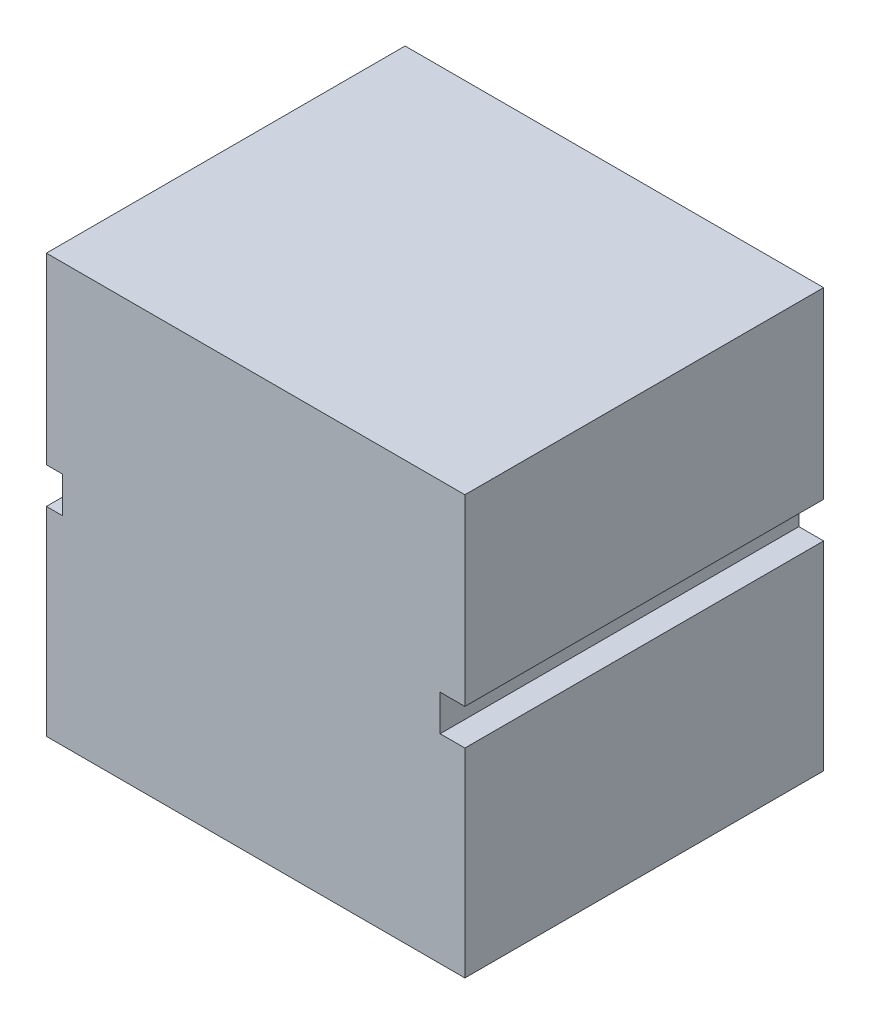
from build123d import *

# Parameters (mm, degrees)
ESQUISSE1_W             = 7
ESQUISSE1_H             = 7
BOSS_EXTRU_1_DEPTH      = 6
ESQUISSE2_W             = 0.413980681
ESQUISSE2_H             = 0.602508534
ESQUISSE2_W_2           = 0.26702738
ENL_V_MAT_EXTRU_1_DEPTH = 7


with BuildPart() as part:
    # Esquisse1 → Boss.-Extru.1 (new body)
    with BuildSketch(Plane.XY):
        with Locations((3.5, 3.5)):
            Rectangle(ESQUISSE1_W, ESQUISSE1_H)
    extrude(amount=BOSS_EXTRU_1_DEPTH)

    # Esquisse2 → Enlèv. mat.-Extru.1 (cut, through all)
    with BuildSketch(Plane(origin=(0, 0, 0), x_dir=(-1, 0, 0), z_dir=(0, 0, -1))):
        with Locations((-6.79300966, 3.632257971)):
            Rectangle(ESQUISSE2_W, ESQUISSE2_H)
        with Locations((-0.13351369, 3.632257971)):
            Rectangle(ESQUISSE2_W_2, ESQUISSE2_H)
    extrude(amount=-ENL_V_MAT_EXTRU_1_DEPTH, mode=Mode.SUBTRACT)


solid = part.part
